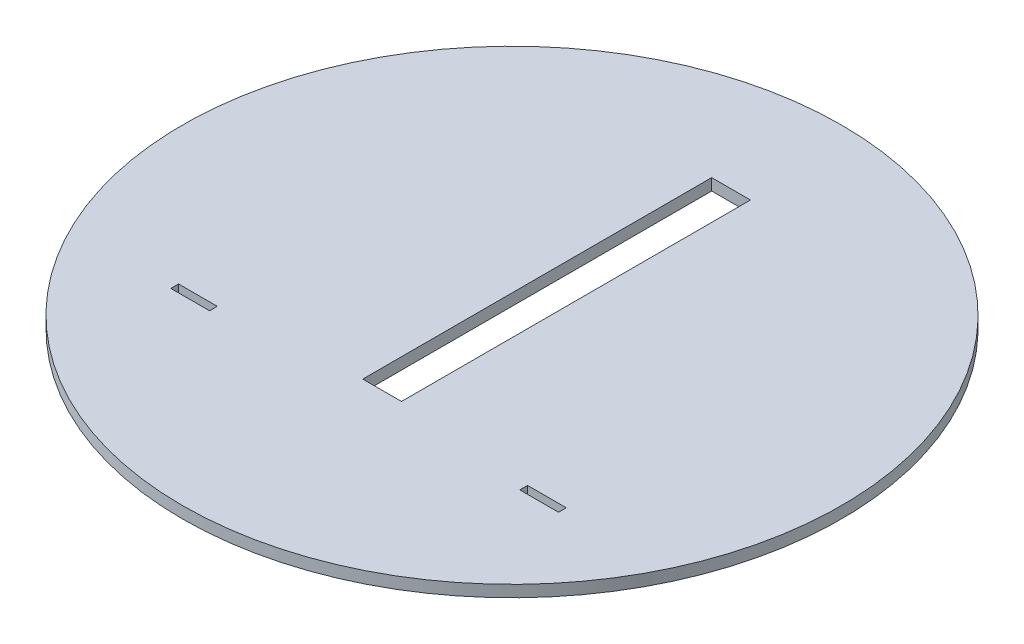
from build123d import *

# Parameters (mm, degrees)
SKETCH1_R           = 8.5
BOSS_EXTRUDE1_DEPTH = 0.15
CUT_EXTRUDE1_REACH  = 2.3
SKETCH2_W           = 1
SKETCH2_H           = 9
SKETCH2_H_2         = 0.2


with BuildPart() as part:
    # Sketch1 → Boss-Extrude1 (new body, symmetric)
    with BuildSketch(Plane(origin=(0, 0, 0), x_dir=(1, 0, 0), z_dir=(0, 1, 0))):
        Circle(SKETCH1_R)
    extrude(amount=BOSS_EXTRUDE1_DEPTH, both=True)

    # Sketch2 → Cut-Extrude1 (cut, up to next)
    with BuildSketch(Plane(origin=(0, 0.15, 0), x_dir=(1, 0, 0), z_dir=(0, 1, 0)), mode=Mode.PRIVATE) as cut_extrude1_sk1:
        with Locations((0, 1.15)):
            Rectangle(SKETCH2_W, SKETCH2_H)
    cut_extrude1_tool1 = extrude(cut_extrude1_sk1.sketch, amount=-CUT_EXTRUDE1_REACH, mode=Mode.PRIVATE) & part.part
    add(cut_extrude1_tool1.solids().sort_by_distance((0, 0.15, -1.15))[0], mode=Mode.SUBTRACT)
    # Sketch2 → Cut-Extrude1 (cut, up to next)
    with BuildSketch(Plane(origin=(0, 0.15, 0), x_dir=(1, 0, 0), z_dir=(0, 1, 0)), mode=Mode.PRIVATE) as cut_extrude1_sk2:
        with Locations((4.5, -3.7)):
            Rectangle(SKETCH2_W, SKETCH2_H_2)
    cut_extrude1_tool2 = extrude(cut_extrude1_sk2.sketch, amount=-CUT_EXTRUDE1_REACH, mode=Mode.PRIVATE) & part.part
    add(cut_extrude1_tool2.solids().sort_by_distance((4.5, 0.15, 3.7))[0], mode=Mode.SUBTRACT)
    # Sketch2 → Cut-Extrude1 (cut, up to next)
    with BuildSketch(Plane(origin=(0, 0.15, 0), x_dir=(1, 0, 0), z_dir=(0, 1, 0)), mode=Mode.PRIVATE) as cut_extrude1_sk3:
        with Locations((-4.5, -3.7)):
            Rectangle(SKETCH2_W, SKETCH2_H_2)
    cut_extrude1_tool3 = extrude(cut_extrude1_sk3.sketch, amount=-CUT_EXTRUDE1_REACH, mode=Mode.PRIVATE) & part.part
    add(cut_extrude1_tool3.solids().sort_by_distance((-4.5, 0.15, 3.7))[0], mode=Mode.SUBTRACT)


solid = part.part
